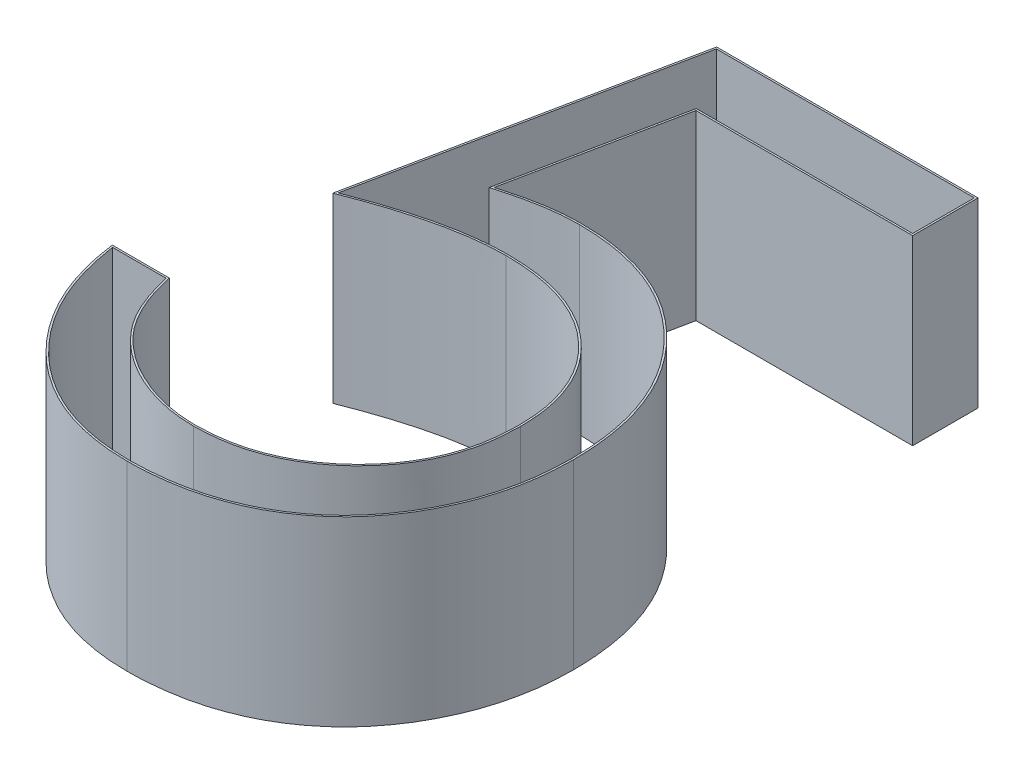
from build123d import *

# Parameters (mm, degrees)
BOSS_EXTRUDE1_DEPTH = 1
CUT_EXTRUDE1_DEPTH  = 1


with BuildPart() as part:
    # Sketch1 → Boss-Extrude1 (new body)
    with BuildSketch(Plane(origin=(0, 0, 0), x_dir=(1, 0, 0), z_dir=(0, 1, 0))):
        with BuildLine():
            Line((2.333333333, 3.5), (2.333333333, 3.141025641))
            Line((2.333333333, 3.141025641), (1.142828526, 3.141025641))
            Line((1.142828526, 3.141025641), (0.954226763, 2.220452724))
            add(Edge.make_bspline(
                [(0.954226763, 2.220452724), (0.991282637, 2.230682996), (1.063072533, 2.25050253), (1.169032394, 2.2725083), (1.269624597, 2.285773744), (1.334899968, 2.287585055), (1.366486378, 2.288461538)],
                knots=[0, 0, 0, 0, 0.000115302, 0.000223379, 0.000324431, 0.000419176, 0.000419176, 0.000419176, 0.000419176], degree=3))
            add(Edge.make_bspline(
                [(1.366486378, 2.288461538), (1.405570118, 2.287615603), (1.482418515, 2.285952282), (1.594857462, 2.269980432), (1.702190355, 2.244840518), (1.804192726, 2.209719996), (1.901053276, 2.164810263), (1.991880838, 2.108710322), (2.078038751, 2.043176991), (2.157981345, 1.967831979), (2.230505653, 1.884910363), (2.294271643, 1.795752492), (2.348434233, 1.701224829), (2.391994988, 1.600424221), (2.426779322, 1.494465067), (2.449931317, 1.382232485), (2.465348026, 1.264784365), (2.467070412, 1.184479795), (2.467948718, 1.143529647)],
                knots=[0, 0, 0, 0, 0.00011719, 0.000230425, 0.000339944, 0.000447481, 0.000553499, 0.000659556, 0.000767111, 0.000877722, 0.000988528, 0.001097091, 0.001206056, 0.001314692, 0.001425996, 0.001539995, 0.001658004, 0.001780798, 0.001780798, 0.001780798, 0.001780798], degree=3))
            add(Edge.make_bspline(
                [(2.467948718, 1.143529647), (2.467283643, 1.115007427), (2.46596248, 1.05834844), (2.459243892, 0.974204239), (2.446308176, 0.891841406), (2.428940452, 0.811249014), (2.406398034, 0.732579642), (2.37910898, 0.655608114), (2.345712953, 0.580813507), (2.309081578, 0.507488112), (2.2678351, 0.437289605), (2.222056592, 0.371640618), (2.173691101, 0.309556337), (2.121649716, 0.251702604), (2.06544872, 0.198459586), (2.005768754, 0.149511304), (1.943086035, 0.104029974), (1.876430792, 0.063861779), (1.807288309, 0.026898823), (1.734660092, -0.003424715), (1.660199392, -0.030535243), (1.582834516, -0.05214477), (1.502740703, -0.069077325), (1.419785928, -0.080577925), (1.334405258, -0.088954363), (1.276530245, -0.08947872), (1.247295673, -0.08974359)],
                knots=[0, 0, 0, 0, 8.5583e-05, 0.000170009, 0.000253005, 0.000335518, 0.000417186, 0.000498352, 0.000580291, 0.000662755, 0.000744161, 0.000824288, 0.000902692, 0.000980133, 0.001057498, 0.001134702, 0.00121156, 0.001289599, 0.001368002, 0.001446531, 0.001525481, 0.001605609, 0.001687289, 0.001770875, 0.001856759, 0.001944425, 0.001944425, 0.001944425, 0.001944425], degree=3))
            add(Edge.make_bspline(
                [(1.247295673, -0.08974359), (1.212421492, -0.089052752), (1.143810662, -0.08769361), (1.043290095, -0.073475124), (0.946575489, -0.053111208), (0.854445388, -0.022474938), (0.766074124, 0.015912357), (0.682651406, 0.064428528), (0.60204563, 0.119407632), (0.527533593, 0.184287985), (0.45837748, 0.255203667), (0.396470971, 0.332161308), (0.341337394, 0.41389075), (0.293859647, 0.500788904), (0.253361626, 0.592627435), (0.221546638, 0.689750436), (0.195868283, 0.79165044), (0.185004862, 0.86180395), (0.179487179, 0.897435897)],
                knots=[0, 0, 0, 0, 0.000104552, 0.000205693, 0.000304023, 0.000400691, 0.00049644, 0.000592535, 0.000689779, 0.000788716, 0.000888377, 0.000986596, 0.001084603, 0.001183757, 0.001283279, 0.001385267, 0.001490017, 0.001598135, 0.001598135, 0.001598135, 0.001598135], degree=3))
            Line((0.179487179, 0.897435897), (0.493589744, 0.897435897))
            add(Edge.make_bspline(
                [(0.493589744, 0.897435897), (0.501318301, 0.864059445), (0.516173017, 0.79990805), (0.548778766, 0.709776709), (0.588644642, 0.629457485), (0.63604899, 0.557887902), (0.692599021, 0.495478905), (0.757128449, 0.439861843), (0.829476173, 0.389686713), (0.909869402, 0.347863946), (0.994682482, 0.312195193), (1.083449692, 0.288443498), (1.173754038, 0.271742605), (1.234832408, 0.270070844), (1.26552484, 0.269230769)],
                knots=[0, 0, 0, 0, 0.000102709, 0.000197412, 0.000286774, 0.000371169, 0.000454082, 0.000538572, 0.000626283, 0.000717552, 0.000809994, 0.00090168, 0.00099274, 0.001084718, 0.001084718, 0.001084718, 0.001084718], degree=3))
            add(Edge.make_bspline(
                [(1.26552484, 0.269230769), (1.295483284, 0.270051547), (1.354471706, 0.271667666), (1.441283093, 0.284106678), (1.525095967, 0.303264249), (1.605083324, 0.331934104), (1.682644864, 0.366778822), (1.755818634, 0.411493898), (1.826721511, 0.462953917), (1.893149645, 0.521910547), (1.953989094, 0.586880241), (2.007745215, 0.656357635), (2.052522128, 0.730474481), (2.090256237, 0.807947634), (2.118909536, 0.889626191), (2.139350517, 0.975127366), (2.151353576, 1.064662347), (2.153004756, 1.125731656), (2.153846154, 1.156850962)],
                knots=[0, 0, 0, 0, 8.9842e-05, 0.0001769, 0.000262612, 0.000347317, 0.000431396, 0.000517249, 0.000604055, 0.000693954, 0.000783242, 0.000870748, 0.000956963, 0.001042571, 0.001128832, 0.00121607, 0.001305907, 0.001399251, 0.001399251, 0.001399251, 0.001399251], degree=3))
            add(Edge.make_bspline(
                [(2.153846154, 1.156850962), (2.153187674, 1.184926713), (2.151898795, 1.239881002), (2.141368224, 1.320280209), (2.123051252, 1.396353251), (2.097627372, 1.468467485), (2.065347864, 1.536690927), (2.025901552, 1.601093987), (1.978548154, 1.660827821), (1.924456265, 1.715920374), (1.865198224, 1.766765249), (1.799754482, 1.810109336), (1.729494555, 1.846573253), (1.655264956, 1.878041252), (1.575300057, 1.900641997), (1.491183425, 1.917609882), (1.402006717, 1.927425245), (1.341036028, 1.928787134), (1.309695513, 1.929487179)],
                knots=[0, 0, 0, 0, 8.4208e-05, 0.000164824, 0.000242709, 0.000318547, 0.000393815, 0.000468731, 0.000544614, 0.00062196, 0.000700062, 0.000778428, 0.000856831, 0.000937299, 0.001019835, 0.001105635, 0.00119452, 0.001288536, 0.001288536, 0.001288536, 0.001288536], degree=3))
            add(Edge.make_bspline(
                [(1.309695513, 1.929487179), (1.282566584, 1.928906588), (1.226552229, 1.927707815), (1.140629402, 1.918881318), (1.050337679, 1.904642024), (0.956023183, 1.885055776), (0.857402675, 1.859424699), (0.754684275, 1.828710199), (0.647652008, 1.7919882), (0.575534284, 1.764255986), (0.538461538, 1.75)],
                knots=[0, 0, 0, 0, 8.1378e-05, 0.000168026, 0.000258858, 0.000355524, 0.000456875, 0.000564457, 0.000677092, 0.000796243, 0.000796243, 0.000796243, 0.000796243], degree=3))
            Line((0.538461538, 1.75), (0.897435897, 3.5))
            Line((0.897435897, 3.5), (2.333333333, 3.5))
        make_face()
    extrude(amount=BOSS_EXTRUDE1_DEPTH)

    # Sketch2 → Cut-Extrude1 (cut)
    with BuildSketch(Plane(origin=(0, 1, 0), x_dir=(1, 0, 0), z_dir=(0, 1, 0))):
        with BuildLine():
            Line((2.323333333, 3.49), (0.905592836, 3.49))
            Line((0.905592836, 3.49), (0.551929218, 1.765889864))
            add(Edge.make_bspline(
                [(0.551929218, 1.765889864), (0.673738922, 1.812668845), (0.797280125, 1.855176325), (0.987231654, 1.902526184), (1.051031765, 1.915357824), (1.179487858, 1.933989775), (1.244413122, 1.938092349), (1.30970019, 1.939489569)],
                knots=[0, 0, 0, 0, 0.5, 0.5, 0.75, 0.75, 1, 1, 1, 1], degree=3))
            add(Edge.make_bspline(
                [(1.30970019, 1.939489569), (1.363847411, 1.938280095), (1.417876344, 1.936372595), (1.52418389, 1.922228814), (1.576669778, 1.91121568), (1.680062555, 1.879871605), (1.730705353, 1.857715885), (1.826011136, 1.806351504), (1.870689785, 1.775667163), (1.953151897, 1.702973355), (1.990539066, 1.663544334), (2.054990667, 1.576409278), (2.082090779, 1.527820945), (2.124480903, 1.427207864), (2.140037318, 1.375049375), (2.159901605, 1.267037946), (2.162559334, 1.211834677), (2.163849324, 1.156833047)],
                knots=[0, 0, 0, 0, 0.125, 0.125, 0.25, 0.25, 0.375, 0.375, 0.5, 0.5, 0.625, 0.625, 0.75, 0.75, 0.875, 0.875, 1, 1, 1, 1], degree=3))
            add(Edge.make_bspline(
                [(2.163849324, 1.156833047), (2.162248178, 1.09761427), (2.159265902, 1.038622106), (2.138782446, 0.923020004), (2.122724368, 0.865482549), (2.055680296, 0.700889907), (1.987728182, 0.602998249), (1.819201533, 0.436899412), (1.719140439, 0.368622939), (1.556731941, 0.30269818), (1.500632253, 0.28612645), (1.384216314, 0.264586062), (1.324812135, 0.260851324), (1.265524972, 0.259227021)],
                knots=[0, 0, 0, 0, 0.125, 0.125, 0.25, 0.25, 0.5, 0.5, 0.75, 0.75, 0.875, 0.875, 1, 1, 1, 1], degree=3))
            add(Edge.make_bspline(
                [(1.265524972, 0.259227021), (1.219938367, 0.26047476), (1.174503659, 0.262546111), (1.085669918, 0.277726511), (1.041789794, 0.288227027), (0.91225602, 0.331150835), (0.830718342, 0.373374515), (0.686098912, 0.482998896), (0.623269223, 0.551283834), (0.53345612, 0.710614012), (0.506302628, 0.798360651), (0.485641733, 0.887435897)],
                knots=[0, 0, 0, 0, 0.125, 0.125, 0.25, 0.25, 0.5, 0.5, 0.75, 0.75, 1, 1, 1, 1], degree=3))
            Line((0.485641733, 0.887435897), (0.191157055, 0.887435897))
            add(Edge.make_bspline(
                [(0.191157055, 0.887435897), (0.211406368, 0.757145276), (0.243536775, 0.630480169), (0.358974915, 0.39276671), (0.436437315, 0.286803018), (0.626737067, 0.105379466), (0.738197612, 0.033819694), (0.92303835, -0.036270399), (0.987200933, -0.0526225), (1.115960495, -0.074639536), (1.1814612, -0.078437476), (1.247349413, -0.079742692)],
                knots=[0, 0, 0, 0, 0.25, 0.25, 0.5, 0.5, 0.75, 0.75, 0.875, 0.875, 1, 1, 1, 1], degree=3))
            add(Edge.make_bspline(
                [(1.247349413, -0.079742692), (1.408635576, -0.078281394), (1.567776608, -0.055759364), (1.794256491, 0.030595591), (1.865728289, 0.066654088), (1.999969309, 0.154511073), (2.063232666, 0.206757735), (2.229552263, 0.379956122), (2.315046252, 0.520653639), (2.401952228, 0.745114707), (2.423207484, 0.823884447), (2.451609765, 0.982328437), (2.456062908, 1.062772615), (2.457946218, 1.143538993)],
                knots=[0, 0, 0, 0, 0.25, 0.25, 0.375, 0.375, 0.5, 0.5, 0.75, 0.75, 0.875, 0.875, 1, 1, 1, 1], degree=3))
            add(Edge.make_bspline(
                [(2.457946218, 1.143538993), (2.456365789, 1.217224275), (2.452803018, 1.290520305), (2.430400351, 1.434112564), (2.413903031, 1.504868779), (2.364641577, 1.643187072), (2.332775805, 1.711173987), (2.255701345, 1.83604232), (2.210931126, 1.894292256), (2.109303532, 2.002677969), (2.053868914, 2.050982466), (1.933833278, 2.13515087), (1.868118497, 2.171236389), (1.73133317, 2.226299522), (1.660590629, 2.24608908), (1.515184925, 2.272751146), (1.440694762, 2.276852996), (1.366516892, 2.278458536)],
                knots=[0, 0, 0, 0, 0.125, 0.125, 0.25, 0.25, 0.375, 0.375, 0.5, 0.5, 0.625, 0.625, 0.75, 0.75, 0.875, 0.875, 1, 1, 1, 1], degree=3))
            add(Edge.make_bspline(
                [(1.366516892, 2.278458536), (1.331224527, 2.277479205), (1.295887727, 2.276466299), (1.225531386, 2.270097376), (1.19049003, 2.265009201), (1.119542574, 2.252164033), (1.083606152, 2.244213472), (1.047958734, 2.235226423), (1.012208016, 2.22621333), (0.976694104, 2.216281344), (0.941154273, 2.206469616)],
                knots=[0, 0, 0, 0, 0.000105918, 0.000105918, 0.000211961, 0.000211961, 0.000322256, 0.000322256, 0.000322256, 0.000432826, 0.000432826, 0.000432826, 0.000432826], degree=3))
            Line((0.941154273, 2.206469616), (1.134669559, 3.151025641))
            Line((1.134669559, 3.151025641), (2.323333333, 3.151025641))
            Line((2.323333333, 3.151025641), (2.323333333, 3.49))
        make_face()
    extrude(amount=-CUT_EXTRUDE1_DEPTH, mode=Mode.SUBTRACT)


solid = part.part
